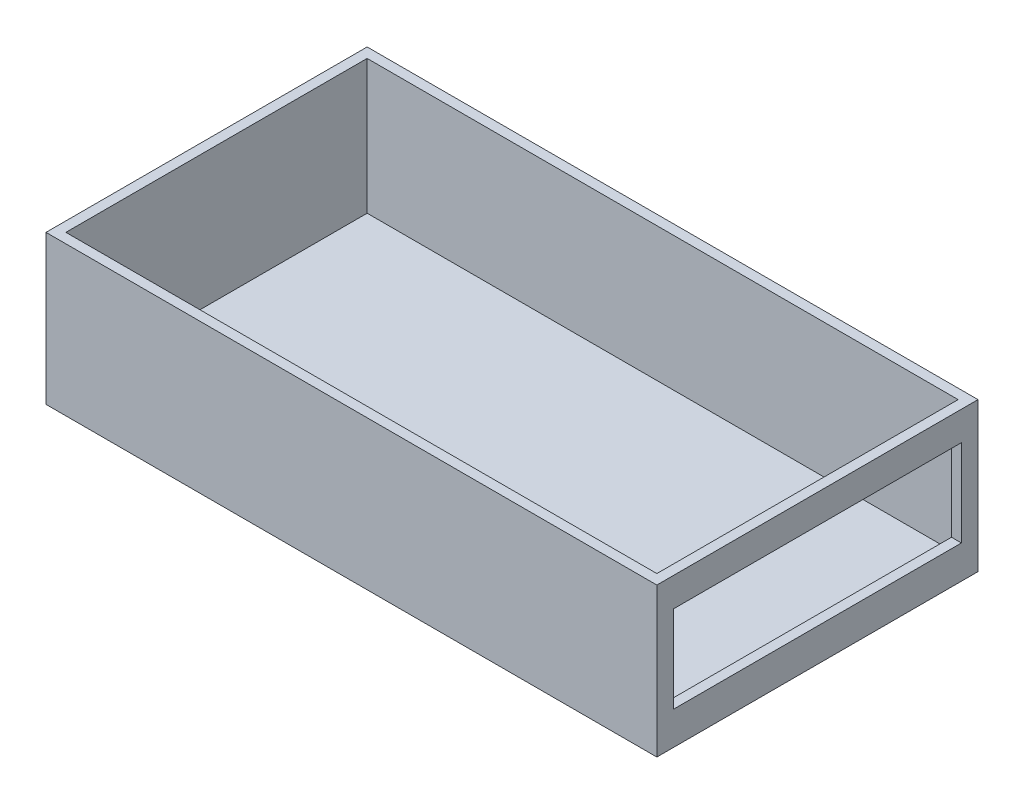
from build123d import *

# Parameters (mm, degrees)
SKETCH1_W           = 73.8
SKETCH1_H           = 38.8
SKETCH1_W_2         = 71.4
SKETCH1_H_2         = 36.4
BOSS_EXTRUDE1_DEPTH = 1.8
SKETCH1_3_W         = 73.8
SKETCH1_3_H         = 38.8
SKETCH1_3_W_2       = 71.4
SKETCH1_3_H_2       = 36.4
BOSS_EXTRUDE2_DEPTH = 18
SKETCH2_W           = 34.8
SKETCH2_H           = 10.5
CUT_EXTRUDE1_DEPTH  = 1.2


with BuildPart() as part:
    # Sketch1 → Boss-Extrude1 (new body)
    with BuildSketch(Plane(origin=(0, 0, 0), x_dir=(1, 0, 0), z_dir=(0, 1, 0))):
        Rectangle(SKETCH1_W, SKETCH1_H)
        Rectangle(SKETCH1_W_2, SKETCH1_H_2, mode=Mode.SUBTRACT)
        Rectangle(SKETCH1_W_2, SKETCH1_H_2)
    extrude(amount=BOSS_EXTRUDE1_DEPTH)

    # Sketch1_3 → Boss-Extrude2 (add)
    with BuildSketch(Plane(origin=(0, 0, 0), x_dir=(1, 0, 0), z_dir=(0, 1, 0))):
        Rectangle(SKETCH1_3_W, SKETCH1_3_H)
        Rectangle(SKETCH1_3_W_2, SKETCH1_3_H_2, mode=Mode.SUBTRACT)
    extrude(amount=BOSS_EXTRUDE2_DEPTH)

    # Sketch2 → Cut-Extrude1 (cut)
    with BuildSketch(Plane(origin=(36.9, 0, 0), x_dir=(0, 0, -1), z_dir=(1, 0, 0))):
        with Locations((0, 9.25)):
            Rectangle(SKETCH2_W, SKETCH2_H)
    extrude(amount=-CUT_EXTRUDE1_DEPTH, mode=Mode.SUBTRACT)


solid = part.part
